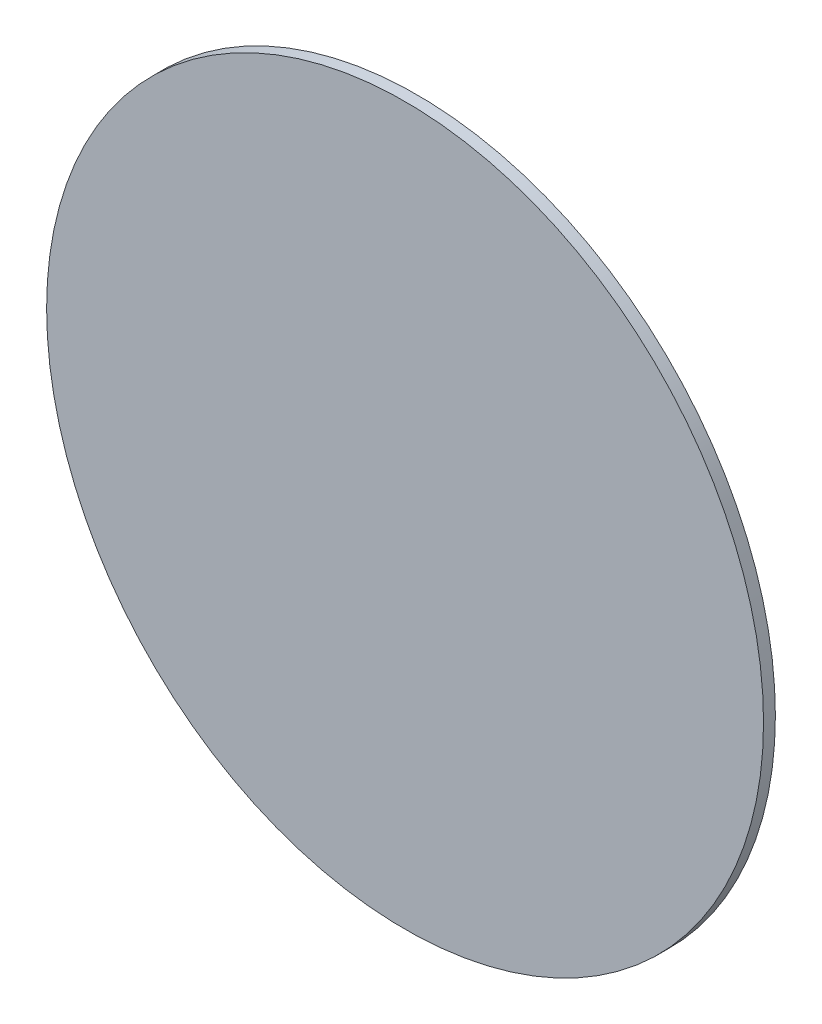
from build123d import *

# Parameters (mm, degrees)
SKETCH1_R           = 60.5
BOSS_EXTRUDE1_DEPTH = 2


with BuildPart() as part:
    # Sketch1 → Boss-Extrude1 (new body)
    with BuildSketch(Plane.XY):
        Circle(SKETCH1_R)
    extrude(amount=BOSS_EXTRUDE1_DEPTH)


solid = part.part
